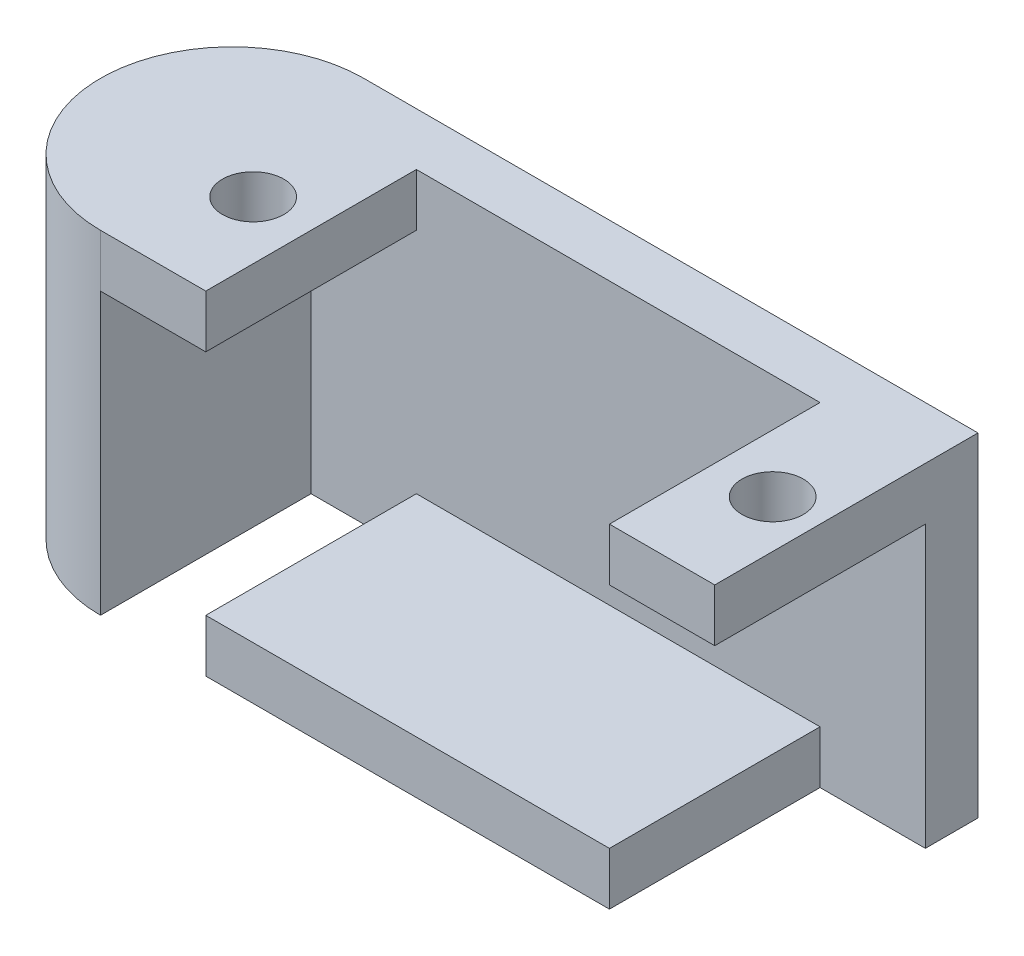
from build123d import *

# Parameters (mm, degrees)
BOSS_EXTRU_1_DEPTH      = 19
ENL_V_MAT_EXTRU_2_DEPTH = 12
ESQUISSE4_R             = 1.75
ENL_V_MAT_EXTRU_3_DEPTH = 12
ESQUISSE5_R             = 1.25
BOSS_EXTRU_2_DEPTH      = 3


with BuildPart() as part:
    # Esquisse1 → Boss.-Extru.1 (new body)
    with BuildSketch(Plane(origin=(0, 0, 0), x_dir=(1, 0, 0), z_dir=(0, 1, 0))):
        with BuildLine():
            Line((0, 0), (35, 0))
            Line((35, 0), (35, 15))
            Line((35, 15), (0, 15))
            ThreePointArc((0, 15), (-7.5, 7.5), (0, 0))
        make_face()
    extrude(amount=BOSS_EXTRU_1_DEPTH)

    # Esquisse3 → Enlèv. mat.-Extru.2 (cut)
    with BuildSketch(Plane.XY):
        Polygon((6, 19), (29, 19), (29, 16), (35, 16), (35, 3.144779012), (35, 0), (29, 0), (29, 3), (6, 3), (6, 0), (0, 0), (0, 3.824764885), (0, 16), (6, 16), align=None)
    extrude(amount=-ENL_V_MAT_EXTRU_2_DEPTH, mode=Mode.SUBTRACT)

    # Esquisse4 → Enlèv. mat.-Extru.3 (cut)
    with BuildSketch(Plane(origin=(0, 19, 0), x_dir=(1, 0, 0), z_dir=(0, 1, 0))):
        with Locations((32.3, 6)):
            Circle(ESQUISSE4_R)
        with Locations((2.7, 6)):
            Circle(ESQUISSE4_R)
    extrude(amount=-ENL_V_MAT_EXTRU_3_DEPTH, mode=Mode.SUBTRACT)

    # Esquisse5 → Boss.-Extru.2 (add)
    with BuildSketch(Plane.XZ):
        with Locations((23, -6)):
            Circle(ESQUISSE5_R)
    extrude(amount=BOSS_EXTRU_2_DEPTH)


solid = part.part
